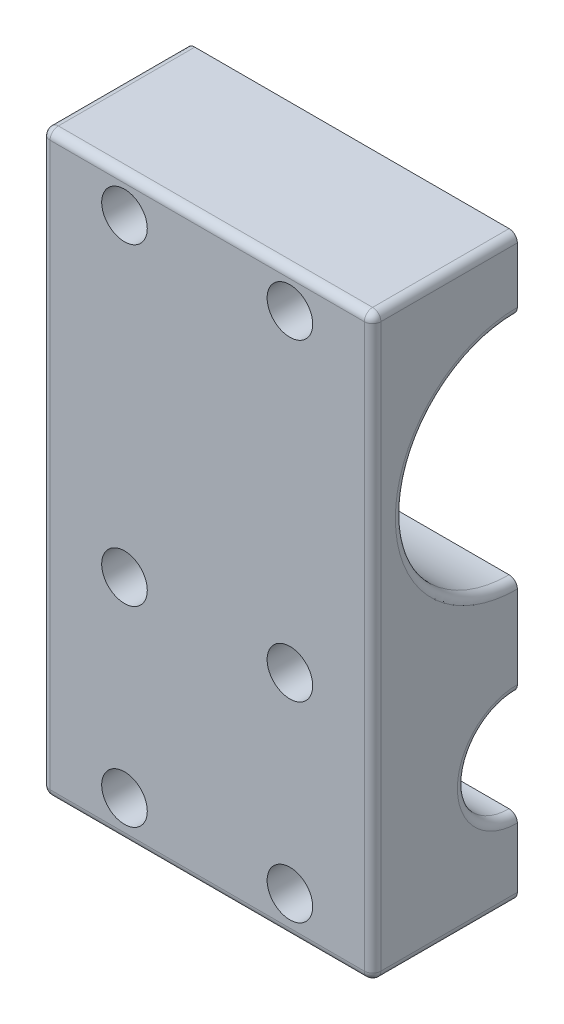
from build123d import *

# Parameters (mm, degrees)
SKETCH1_W           = 44.45
SKETCH1_H           = 88.9
SKETCH1_R           = 7.9375
SKETCH1_R_2         = 17.4625
BOSS_EXTRUDE1_DEPTH = 50.8
SKETCH5_R           = 2.032
CUT_EXTRUDE1_DEPTH  = 112.622813528
SKETCH5_3_R         = 3.5
CUT_EXTRUDE2_DEPTH  = 15.1765
CUT_EXTRUDE3_DEPTH  = 2.54
FILLET1_R           = 1.27


with BuildPart() as part:
    # Sketch1 → Boss-Extrude1 (new body)
    with BuildSketch(Plane(origin=(0, 0, 0), x_dir=(0, 0, -1), z_dir=(1, 0, 0))):
        with Locations((22.225, 44.45)):
            Rectangle(SKETCH1_W, SKETCH1_H)
        with Locations(Location((22.225, 19.685, 0), (0, 0, 180))):
            Circle(SKETCH1_R, mode=Mode.SUBTRACT)
        with Locations(Location((22.225, 60.325, 0), (0, 0, 180))):
            Circle(SKETCH1_R_2, mode=Mode.SUBTRACT)
    extrude(amount=BOSS_EXTRUDE1_DEPTH)

    # Sketch5 → Cut-Extrude1 (cut, through all)
    with BuildSketch(Plane.XY):
        with Locations((12.7, 83.34375)):
            Circle(SKETCH5_R)
        with Locations((12.7, 35.2425)):
            Circle(SKETCH5_R)
        with Locations((38.1, 83.34375)):
            Circle(SKETCH5_R)
        with Locations((38.1, 35.2425)):
            Circle(SKETCH5_R)
        with Locations((12.7, 5.87375)):
            Circle(SKETCH5_R)
        with Locations((38.1, 5.87375)):
            Circle(SKETCH5_R)
    extrude(amount=-CUT_EXTRUDE1_DEPTH, mode=Mode.SUBTRACT)

    # Sketch5_3 → Cut-Extrude2 (cut)
    with BuildSketch(Plane.XY):
        with Locations((38.1, 35.2425)):
            Circle(SKETCH5_3_R)
        with Locations((12.7, 83.34375)):
            Circle(SKETCH5_3_R)
        with Locations((38.1, 83.34375)):
            Circle(SKETCH5_3_R)
        with Locations((12.7, 35.2425)):
            Circle(SKETCH5_3_R)
        with Locations((38.1, 5.87375)):
            Circle(SKETCH5_3_R)
        with Locations((12.7, 5.87375)):
            Circle(SKETCH5_3_R)
    extrude(amount=-CUT_EXTRUDE2_DEPTH, mode=Mode.SUBTRACT)

    # Sketch6 → Cut-Extrude3 (cut)
    with BuildSketch(Plane(origin=(0, 0, -44.45), x_dir=(-1, 0, 0), z_dir=(0, 0, -1))):
        Polygon((-8.636, 83.34375), (-10.668, 86.863277241), (-14.732, 86.863277241), (-16.764, 83.34375), (-14.732, 79.824222759), (-10.668, 79.824222759), align=None)
        Polygon((-34.036, 83.34375), (-36.068, 86.863277241), (-40.132, 86.863277241), (-42.164, 83.34375), (-40.132, 79.824222759), (-36.068, 79.824222759), align=None)
        Polygon((-34.036, 35.2425), (-36.068, 38.762027241), (-40.132, 38.762027241), (-42.164, 35.2425), (-40.132, 31.722972759), (-36.068, 31.722972759), align=None)
        Polygon((-8.636, 35.2425), (-10.668, 38.762027241), (-14.732, 38.762027241), (-16.764, 35.2425), (-14.732, 31.722972759), (-10.668, 31.722972759), align=None)
        Polygon((-8.636, 5.87375), (-10.668, 9.393277241), (-14.732, 9.393277241), (-16.764, 5.87375), (-14.732, 2.354222759), (-10.668, 2.354222759), align=None)
        Polygon((-34.036, 5.87375), (-36.068, 9.393277241), (-40.132, 9.393277241), (-42.164, 5.87375), (-40.132, 2.354222759), (-36.068, 2.354222759), align=None)
    extrude(amount=-CUT_EXTRUDE3_DEPTH, mode=Mode.SUBTRACT)

    # Fillet1
    fillet1_edges = [part.edges().sort_by_distance(p)[0] for p in [
        (0, 60.325, -39.6875),
        (50.8, 60.325, -39.6875),
        (50.8, 88.9, -22.225),
        (0, 19.685, -30.1625),
        (50.8, 19.685, -30.1625),
        (50.8, 44.45, 0),
        (50.8, 0, -22.225),
        (0, 44.45, 0),
        (0, 88.9, -22.225),
        (0, 44.45, -44.45),
        (0, 0, -22.225),
        (25.4, 0, 0),
        (25.4, 88.9, 0),
        (25.4, 88.9, -44.45),
        (25.4, 0, -44.45),
        (50.8, 44.45, -44.45),
    ]]
    fillet(fillet1_edges, radius=FILLET1_R)

    # SurfaceCut1
    split(bisect_by=Plane.XY.offset(-22.225), keep=Keep.TOP)


solid = part.part
